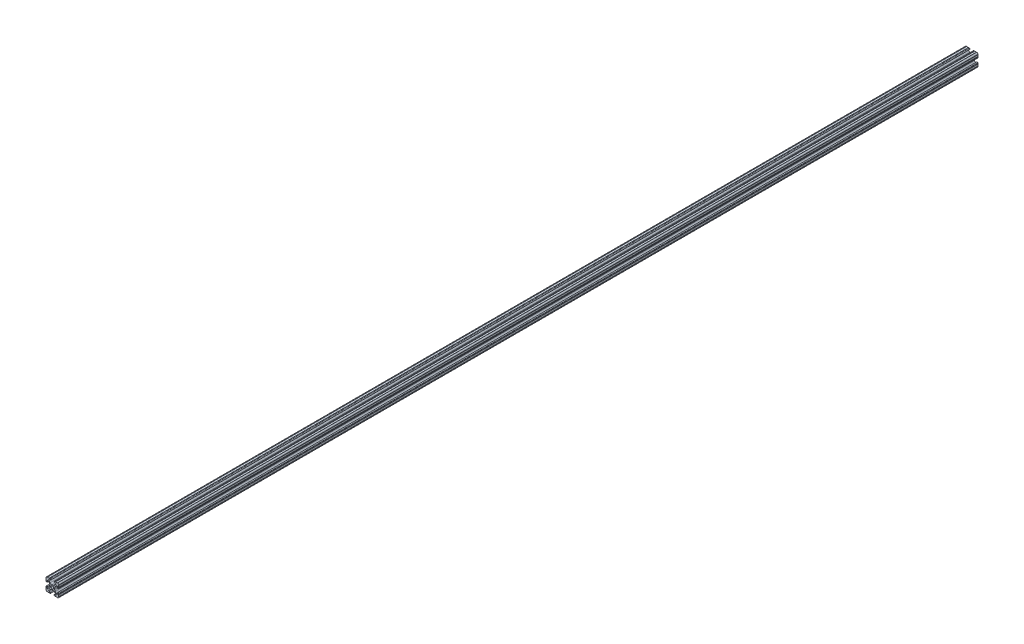
from build123d import *

# Parameters (mm, degrees)
SKETCH3_R      = 2.6035
EXTRUDE1_DEPTH = 914.4


with BuildPart() as part:
    # Sketch3 → Extrude1 (new body, symmetric)
    with BuildSketch(Plane.XY):
        with BuildLine():
            Line((-1.115277175, 4.5085), (1.115277175, 4.5085))
            ThreePointArc((1.115277175, 4.5085), (2.806584872, 4.844922018), (4.240406305, 5.80297087))
            Line((4.240406305, 5.80297087), (7.148423664, 8.710988229))
            ThreePointArc((7.148423664, 8.710988229), (7.349906316, 9.772227925), (6.436353897, 10.348636575))
            Line((6.436353897, 10.348636575), (4.381960454, 10.276895575))
            ThreePointArc((4.381960454, 10.276895575), (3.239173075, 11.342562046), (4.304839546, 12.485349424))
            Line((4.304839546, 12.485349424), (5.728246175, 12.535055879))
            ThreePointArc((5.728246175, 12.535055879), (6.054756855, 12.230579745), (6.35923299, 12.557090424))
            Line((6.35923299, 12.557090424), (9.782092278, 12.676619304))
            ThreePointArc((9.782092278, 12.676619304), (10.108602958, 12.37214317), (10.413079092, 12.69865385))
            ThreePointArc((10.413079092, 12.69865385), (12.052764565, 12.052764565), (12.69865385, 10.413079092))
            ThreePointArc((12.69865385, 10.413079092), (12.37214317, 10.108602958), (12.676619304, 9.782092278))
            Line((12.676619304, 9.782092278), (12.557090424, 6.35923299))
            ThreePointArc((12.557090424, 6.35923299), (12.230579745, 6.054756855), (12.535055879, 5.728246175))
            Line((12.535055879, 5.728246175), (12.485349424, 4.304839546))
            ThreePointArc((12.485349424, 4.304839546), (11.342562046, 3.239173075), (10.276895575, 4.381960454))
            Line((10.276895575, 4.381960454), (10.348636575, 6.436353897))
            ThreePointArc((10.348636575, 6.436353897), (9.772227925, 7.349906316), (8.710988229, 7.148423664))
            Line((8.710988229, 7.148423664), (5.80297087, 4.240406305))
            ThreePointArc((5.80297087, 4.240406305), (4.844922018, 2.806584872), (4.5085, 1.115277175))
            Line((4.5085, 1.115277175), (4.5085, -1.115277175))
            ThreePointArc((4.5085, -1.115277175), (4.844922018, -2.806584872), (5.80297087, -4.240406305))
            Line((5.80297087, -4.240406305), (8.710988229, -7.148423664))
            ThreePointArc((8.710988229, -7.148423664), (9.772227925, -7.349906316), (10.348636575, -6.436353897))
            Line((10.348636575, -6.436353897), (10.276895575, -4.381960454))
            ThreePointArc((10.276895575, -4.381960454), (11.342562046, -3.239173075), (12.485349424, -4.304839546))
            Line((12.485349424, -4.304839546), (12.535055879, -5.728246175))
            ThreePointArc((12.535055879, -5.728246175), (12.230579745, -6.054756855), (12.557090424, -6.35923299))
            Line((12.557090424, -6.35923299), (12.676619304, -9.782092278))
            ThreePointArc((12.676619304, -9.782092278), (12.37214317, -10.108602958), (12.69865385, -10.413079092))
            ThreePointArc((12.69865385, -10.413079092), (12.052764565, -12.052764565), (10.413079092, -12.69865385))
            ThreePointArc((10.413079092, -12.69865385), (10.108602958, -12.37214317), (9.782092278, -12.676619304))
            Line((9.782092278, -12.676619304), (6.35923299, -12.557090424))
            ThreePointArc((6.35923299, -12.557090424), (6.054756855, -12.230579745), (5.728246175, -12.535055879))
            Line((5.728246175, -12.535055879), (4.304839546, -12.485349424))
            ThreePointArc((4.304839546, -12.485349424), (3.239173075, -11.342562046), (4.381960454, -10.276895575))
            Line((4.381960454, -10.276895575), (6.436353897, -10.348636575))
            ThreePointArc((6.436353897, -10.348636575), (7.349906316, -9.772227925), (7.148423664, -8.710988229))
            Line((7.148423664, -8.710988229), (4.240406305, -5.80297087))
            ThreePointArc((4.240406305, -5.80297087), (2.806584872, -4.844922018), (1.115277175, -4.5085))
            Line((1.115277175, -4.5085), (-1.115277175, -4.5085))
            ThreePointArc((-1.115277175, -4.5085), (-2.806584872, -4.844922018), (-4.240406305, -5.80297087))
            Line((-4.240406305, -5.80297087), (-7.148423664, -8.710988229))
            ThreePointArc((-7.148423664, -8.710988229), (-7.349906316, -9.772227925), (-6.436353897, -10.348636575))
            Line((-6.436353897, -10.348636575), (-4.381960454, -10.276895575))
            ThreePointArc((-4.381960454, -10.276895575), (-3.239173075, -11.342562046), (-4.304839546, -12.485349424))
            Line((-4.304839546, -12.485349424), (-5.728246175, -12.535055879))
            ThreePointArc((-5.728246175, -12.535055879), (-6.054756855, -12.230579745), (-6.35923299, -12.557090424))
            Line((-6.35923299, -12.557090424), (-9.782092278, -12.676619304))
            ThreePointArc((-9.782092278, -12.676619304), (-10.108602958, -12.37214317), (-10.413079092, -12.69865385))
            ThreePointArc((-10.413079092, -12.69865385), (-12.052764565, -12.052764565), (-12.69865385, -10.413079092))
            ThreePointArc((-12.69865385, -10.413079092), (-12.37214317, -10.108602958), (-12.676619304, -9.782092278))
            Line((-12.676619304, -9.782092278), (-12.557090424, -6.35923299))
            ThreePointArc((-12.557090424, -6.35923299), (-12.230579745, -6.054756855), (-12.535055879, -5.728246175))
            Line((-12.535055879, -5.728246175), (-12.485349424, -4.304839546))
            ThreePointArc((-12.485349424, -4.304839546), (-11.342562046, -3.239173075), (-10.276895575, -4.381960454))
            Line((-10.276895575, -4.381960454), (-10.348636575, -6.436353897))
            ThreePointArc((-10.348636575, -6.436353897), (-9.772227925, -7.349906316), (-8.710988229, -7.148423664))
            Line((-8.710988229, -7.148423664), (-5.80297087, -4.240406305))
            ThreePointArc((-5.80297087, -4.240406305), (-4.844922018, -2.806584872), (-4.5085, -1.115277175))
            Line((-4.5085, -1.115277175), (-4.5085, 1.115277175))
            ThreePointArc((-4.5085, 1.115277175), (-4.844922018, 2.806584872), (-5.80297087, 4.240406305))
            Line((-5.80297087, 4.240406305), (-8.710988229, 7.148423664))
            ThreePointArc((-8.710988229, 7.148423664), (-9.772227925, 7.349906316), (-10.348636575, 6.436353897))
            Line((-10.348636575, 6.436353897), (-10.276895575, 4.381960454))
            ThreePointArc((-10.276895575, 4.381960454), (-11.342562046, 3.239173075), (-12.485349424, 4.304839546))
            Line((-12.485349424, 4.304839546), (-12.535055879, 5.728246175))
            ThreePointArc((-12.535055879, 5.728246175), (-12.230579745, 6.054756855), (-12.557090424, 6.35923299))
            Line((-12.557090424, 6.35923299), (-12.676619304, 9.782092278))
            ThreePointArc((-12.676619304, 9.782092278), (-12.37214317, 10.108602958), (-12.69865385, 10.413079092))
            ThreePointArc((-12.69865385, 10.413079092), (-12.052764565, 12.052764565), (-10.413079092, 12.69865385))
            ThreePointArc((-10.413079092, 12.69865385), (-10.108602958, 12.37214317), (-9.782092278, 12.676619304))
            Line((-9.782092278, 12.676619304), (-6.35923299, 12.557090424))
            ThreePointArc((-6.35923299, 12.557090424), (-6.054756855, 12.230579745), (-5.728246175, 12.535055879))
            Line((-5.728246175, 12.535055879), (-4.304839546, 12.485349424))
            ThreePointArc((-4.304839546, 12.485349424), (-3.239173075, 11.342562046), (-4.381960454, 10.276895575))
            Line((-4.381960454, 10.276895575), (-6.436353897, 10.348636575))
            ThreePointArc((-6.436353897, 10.348636575), (-7.349906316, 9.772227925), (-7.148423664, 8.710988229))
            Line((-7.148423664, 8.710988229), (-4.240406305, 5.80297087))
            ThreePointArc((-4.240406305, 5.80297087), (-2.806584872, 4.844922018), (-1.115277175, 4.5085))
        make_face()
        Circle(SKETCH3_R, mode=Mode.SUBTRACT)
    extrude(amount=EXTRUDE1_DEPTH, both=True)


solid = part.part
